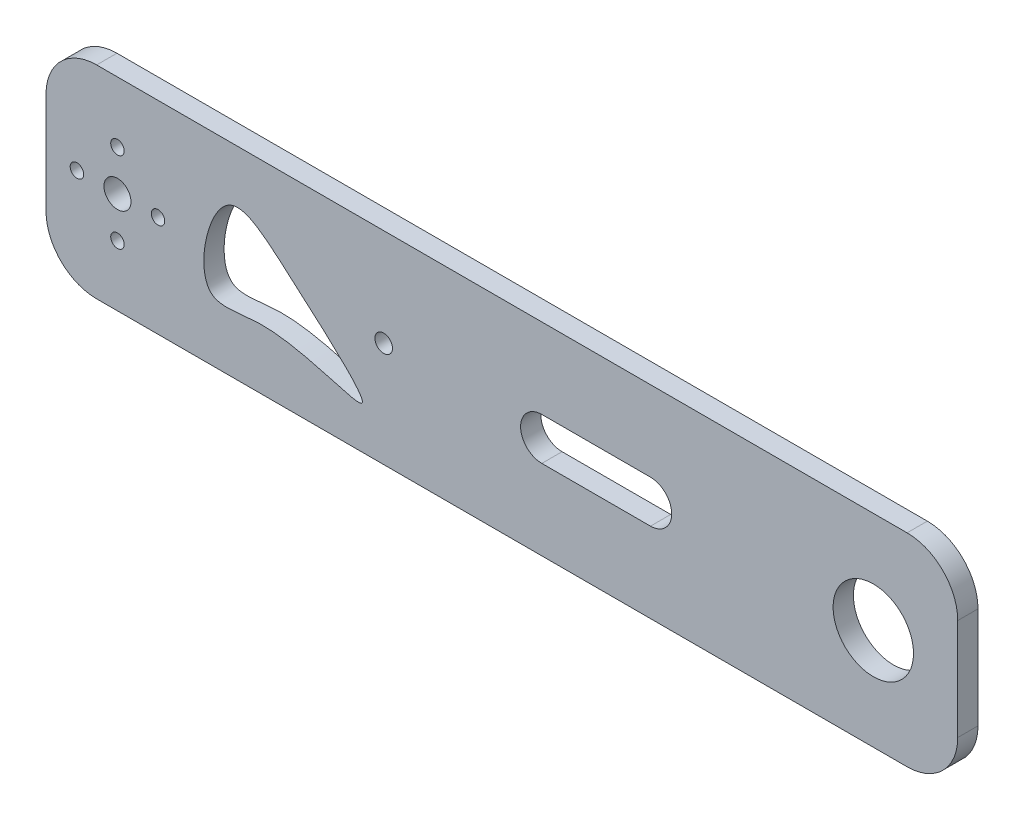
from build123d import *

# Parameters (mm, degrees)
SKETCH1_W           = 270
SKETCH1_H           = 60
BOSS_EXTRUDE1_DEPTH = 3
FILLET1_R           = 15
SKETCH3_R           = 4
SKETCH3_R_2         = 2
CUT_EXTRUDE1_DEPTH  = 8
SKETCH4_R           = 2.6
SKETCH4_R_2         = 11.9
CUT_EXTRUDE2_DEPTH  = 10
CUT_EXTRUDE3_DEPTH  = 10


with BuildPart() as part:
    # Sketch1 → Boss-Extrude1 (new, symmetric)
    with BuildSketch(Plane.XY):
        Rectangle(SKETCH1_W, SKETCH1_H)
    extrude(amount=BOSS_EXTRUDE1_DEPTH, both=True)

    # Fillet1
    fillet1_edges = [part.edges().sort_by_distance(p)[0] for p in [
        (135, -30, 0),
        (-135, -30, 0),
        (-135, 30, 0),
        (135, 30, 0),
    ]]
    fillet(fillet1_edges, radius=FILLET1_R)

    # Sketch3 → Cut-Extrude1 (cut)
    with BuildSketch(Plane.XY.offset(3)):
        with Locations((-113.835271993, 0)):
            Circle(SKETCH3_R)
        with Locations((-113.835271993, 12)):
            Circle(SKETCH3_R_2)
        with Locations((-113.835271993, -12)):
            Circle(SKETCH3_R_2)
        with Locations((-101.835271993, 0)):
            Circle(SKETCH3_R_2)
        with Locations((-125.835271993, 0)):
            Circle(SKETCH3_R_2)
    extrude(amount=-CUT_EXTRUDE1_DEPTH, mode=Mode.SUBTRACT)

    # Sketch4 → Cut-Extrude2 (cut)
    with BuildSketch(Plane.XY.offset(3)):
        with Locations((-35, 1.123266966)):
            Circle(SKETCH4_R)
        with Locations((110, 0)):
            Circle(SKETCH4_R_2)
    extrude(amount=-CUT_EXTRUDE2_DEPTH, mode=Mode.SUBTRACT)

    # Sketch5 → Cut-Extrude3 (cut)
    with BuildSketch(Plane.XY.offset(3)):
        with BuildLine():
            add(Edge.make_bspline(
                [(-86.01823318, -11.605280405), (-90.956175865, -7.27604283), (-84.22937534, 23.092684909), (-60.562452564, 2.39071625), (-27.099149372, -26.622988945), (-65.929752728, -8.617700677), (-83.23545088, -14.045026362), (-86.01823318, -11.605280405)],
                knots=[0, 0, 0, 0, 0.211868543, 0.367136428, 0.629956713, 0.880601281, 1, 1, 1, 1], degree=3))
        make_face()
        with BuildLine():
            Line((11.82961063, 6.280531647), (44.0100176, 6.280531647))
            ThreePointArc((44.0100176, 6.280531647), (50.290549247, 0), (44.0100176, -6.280531647))
            Line((44.0100176, -6.280531647), (11.82961063, -6.280531647))
            ThreePointArc((11.82961063, -6.280531647), (5.549078983, 0), (11.82961063, 6.280531647))
        make_face()
    extrude(amount=-CUT_EXTRUDE3_DEPTH, mode=Mode.SUBTRACT)


solid = part.part
